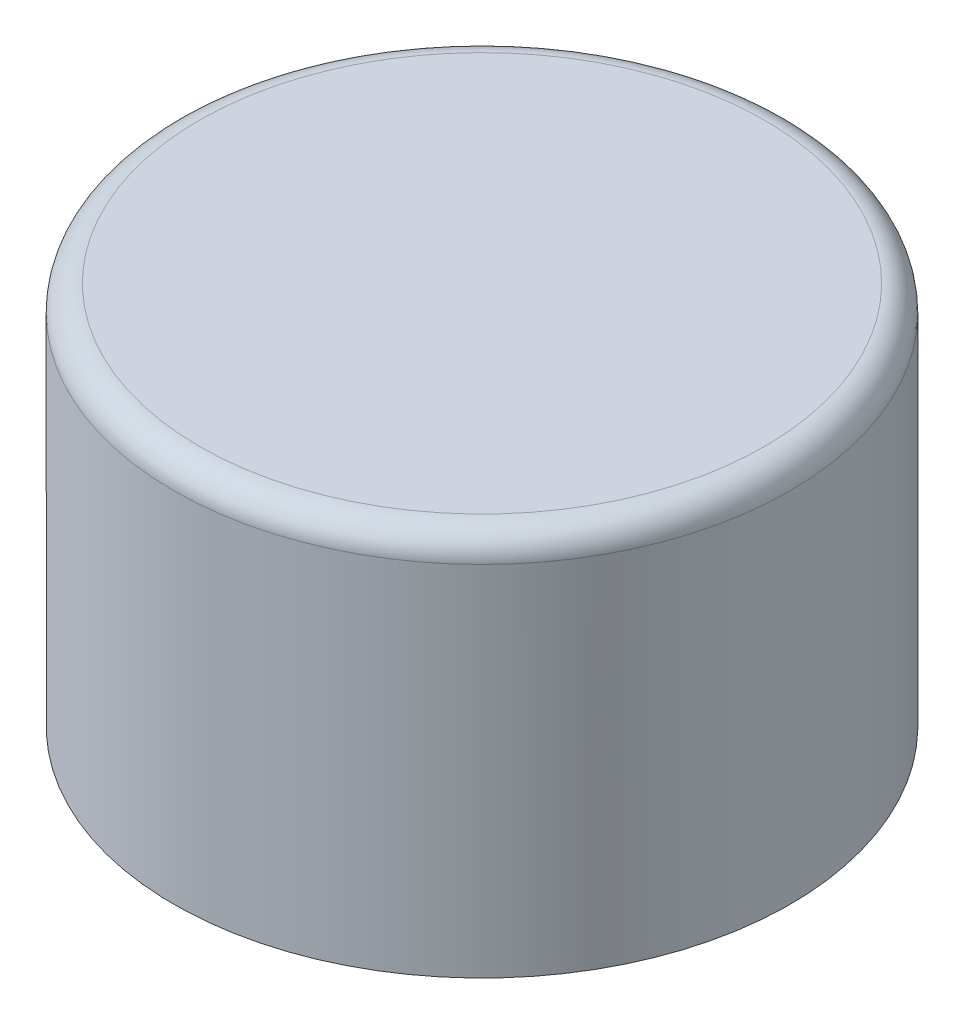
from build123d import *

# Parameters (mm, degrees)
SKETCH1_R           = 30.5943
BOSS_EXTRUDE1_DEPTH = 38.1
SHELL1_T            = -0.254
FILLET1_R           = 2.54
FILLET2_R           = 2.54


with BuildPart() as part:
    # Sketch1 → Boss-Extrude1 (new body)
    with BuildSketch(Plane(origin=(0, 0, 0), x_dir=(1, 0, 0), z_dir=(0, 1, 0))):
        with Locations(Location((0, 0, 0), (0, 0, 90))):
            Circle(SKETCH1_R)
    extrude(amount=BOSS_EXTRUDE1_DEPTH)

    # Shell1
    shell1_openings = [part.faces().sort_by_distance(p)[0] for p in [
        (0, 0, 0),
    ]]
    offset(amount=SHELL1_T, openings=shell1_openings, kind=Kind.INTERSECTION)

    # Fillet1
    fillet1_edges = [part.edges().sort_by_distance(p)[0] for p in [
        (0, 37.846, 30.3403),
    ]]
    fillet(fillet1_edges, radius=FILLET1_R)

    # Fillet2
    fillet2_edges = [part.edges().sort_by_distance(p)[0] for p in [
        (0, 38.1, 30.5943),
    ]]
    fillet(fillet2_edges, radius=FILLET2_R)


solid = part.part
